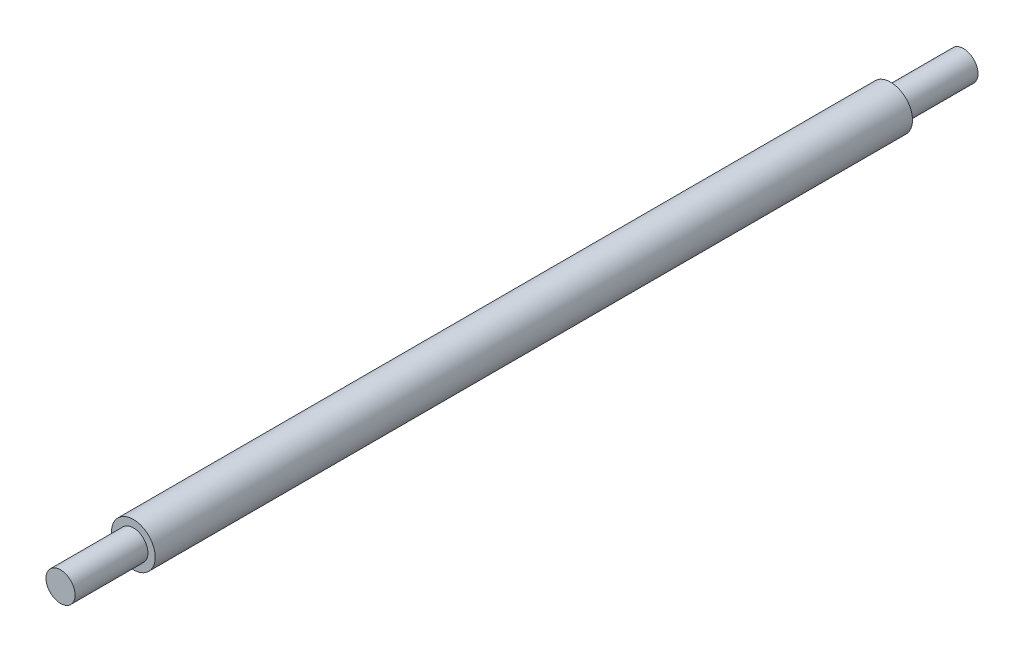
from build123d import *

# Parameters (mm, degrees)
SKETCH1_R           = 3
BOSS_EXTRUDE1_DEPTH = 52
SKETCH2_R           = 2
BOSS_EXTRUDE2_DEPTH = 10
SKETCH3_R           = 2
BOSS_EXTRUDE3_DEPTH = 10


with BuildPart() as part:
    # Sketch1 → Boss-Extrude1 (new body, symmetric)
    with BuildSketch(Plane.XY):
        Circle(SKETCH1_R)
    extrude(amount=BOSS_EXTRUDE1_DEPTH, both=True)

    # Sketch2 → Boss-Extrude2 (add)
    with BuildSketch(Plane.XY.offset(52)):
        Circle(SKETCH2_R)
    extrude(amount=BOSS_EXTRUDE2_DEPTH)

    # Sketch3 → Boss-Extrude3 (add)
    with BuildSketch(Plane(origin=(0, 0, -52), x_dir=(-1, 0, 0), z_dir=(0, 0, -1))):
        Circle(SKETCH3_R)
    extrude(amount=BOSS_EXTRUDE3_DEPTH)


solid = part.part
